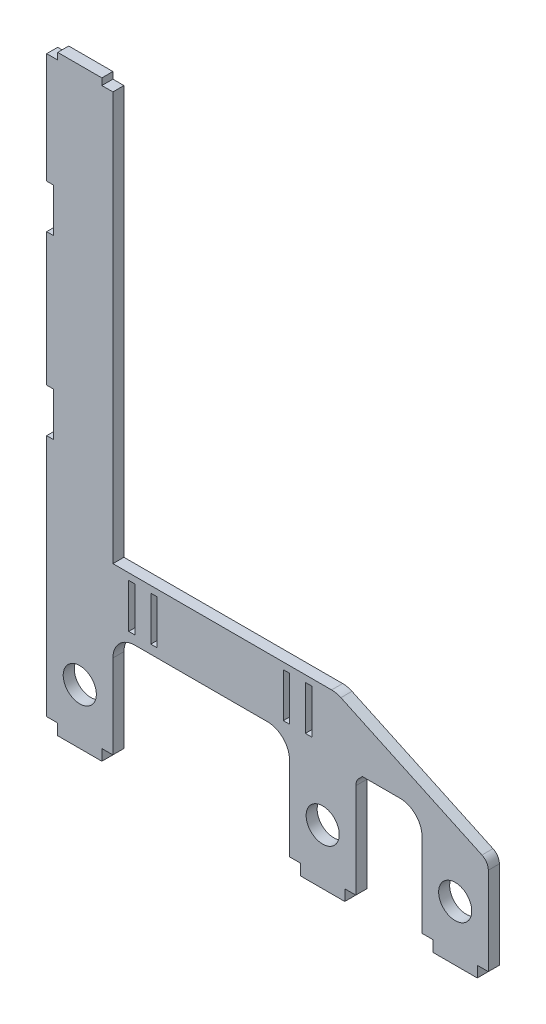
from build123d import *

# Parameters (mm, degrees)
SKETCH1_W           = 2.9
SKETCH1_H           = 20
BOSS_EXTRUDE1_DEPTH = 5
CUT_EXTRUDE1_DEPTH  = 6
FILLET1_R           = 10
SKETCH3_W           = 3
SKETCH3_H           = 19.8
CUT_EXTRUDE2_DEPTH  = 5
LPATTERN1_COUNT     = 2
LPATTERN1_PITCH     = 80
CUT_EXTRUDE3_DEPTH  = 10
CUT_EXTRUDE4_DEPTH  = 5
BOSS_EXTRUDE2_DEPTH = 5
BOSS_EXTRUDE3_DEPTH = 5
FILLET3_R           = 10
FILLET4_R           = 5
SKETCH12_W          = 20
SKETCH12_H          = 5
BOSS_EXTRUDE4_DEPTH = 5
SKETCH13_R          = 7.5
CUT_EXTRUDE6_DEPTH  = 6


with BuildPart() as part:
    # Sketch1 → Boss-Extrude1 (new body)
    with BuildSketch(Plane.XY):
        with BuildLine():
            Line((155, 62.071067812), (155, 65.538881442))
            ThreePointArc((155, 65.538881442), (153.730862151, 68.867645118), (150.567732956, 70.506544805))
            Line((150.567732956, 70.506544805), (34.432267044, 83.779169481))
            ThreePointArc((34.432267044, 83.779169481), (31.269137849, 85.418069168), (30, 88.746832844))
            Line((30, 88.746832844), (30, 260))
            Line((30, 260), (25, 260))
            Line((25, 260), (25, 263))
            Line((25, 263), (5, 263))
            Line((5, 263), (5, 260))
            Line((5, 260), (0, 260))
            Line((0, 260), (0, 0))
            Line((0, 0), (5, 0))
            Line((5, 0), (5, -5))
            Line((5, -5), (25, -5))
            Line((25, -5), (25, 0))
            Line((25, 0), (30, 0))
            Line((30, 0), (30, 40))
            ThreePointArc((30, 40), (31.464466094, 43.535533906), (35, 45))
            Line((35, 45), (105, 45))
            ThreePointArc((105, 45), (108.535533906, 43.535533906), (110, 40))
            Line((110, 40), (110, 0))
            Line((110, 0), (115, 0))
            Line((115, 0), (115, -5))
            Line((115, -5), (135, -5))
            Line((135, -5), (135, 0))
            Line((135, 0), (140, 0))
            Line((140, 0), (140, 42.928932188))
            ThreePointArc((140, 42.928932188), (140.380602337, 44.84234935), (141.464466094, 46.464466094))
            Line((141.464466094, 46.464466094), (153.535533906, 58.535533906))
            ThreePointArc((153.535533906, 58.535533906), (154.619397663, 60.15765065), (155, 62.071067812))
        make_face()
        with Locations((38.6, 62)):
            Rectangle(SKETCH1_W, SKETCH1_H, mode=Mode.SUBTRACT)
        with Locations((48.6, 62)):
            Rectangle(SKETCH1_W, SKETCH1_H, mode=Mode.SUBTRACT)
        with Locations((118.6, 62)):
            Rectangle(SKETCH1_W, SKETCH1_H, mode=Mode.SUBTRACT)
        with Locations((108.6, 62)):
            Rectangle(SKETCH1_W, SKETCH1_H, mode=Mode.SUBTRACT)
    extrude(amount=BOSS_EXTRUDE1_DEPTH)

    # Sketch2 → Cut-Extrude1 (cut, through all)
    with BuildSketch(Plane.XY.offset(5)):
        with BuildLine():
            Line((30, 40), (30, 48))
            Line((30, 48), (110, 48))
            Line((110, 48), (110, 40))
            ThreePointArc((110, 40), (108.535533906, 43.535533906), (105, 45))
            Line((105, 45), (35, 45))
            ThreePointArc((35, 45), (31.464466094, 43.535533906), (30, 40))
        make_face()
    extrude(amount=-CUT_EXTRUDE1_DEPTH, mode=Mode.SUBTRACT)

    # Fillet1
    fillet1_edges = [part.edges().sort_by_distance(p)[0] for p in [
        (30, 48, 2.5),
        (110, 48, 2.5),
    ]]
    fillet(fillet1_edges, radius=FILLET1_R)

    # Sketch3 → Cut-Extrude2 (cut)
    with BuildSketch(Plane(origin=(0, 0, 0), x_dir=(-1, 0, 0), z_dir=(0, 0, -1))):
        with Locations((-1.5, 200.1)):
            Rectangle(SKETCH3_W, SKETCH3_H)
    cut_extrude2 = extrude(amount=-CUT_EXTRUDE2_DEPTH, mode=Mode.SUBTRACT)

    # LPattern1: Cut-Extrude2 ×2
    with Locations(*[(0, -i * LPATTERN1_PITCH, 0) for i in range(1, LPATTERN1_COUNT)]):
        add(cut_extrude2, mode=Mode.SUBTRACT)

    # Sketch4 → Cut-Extrude3 (cut)
    with BuildSketch(Plane.XY.offset(5)):
        with BuildLine():
            Line((30, 88.746832844), (30, 75))
            Line((30, 75), (111.25, 75))
            Line((111.25, 75), (34.432267044, 83.779169481))
            ThreePointArc((34.432267044, 83.779169481), (31.269137849, 85.418069168), (30, 88.746832844))
        make_face()
    extrude(amount=-CUT_EXTRUDE3_DEPTH, mode=Mode.SUBTRACT)

    # Sketch5 → Cut-Extrude4 (cut)
    with BuildSketch(Plane.XY.offset(5)):
        with BuildLine():
            Line((150.567732956, 70.506544805), (134.9100099, 72.295998869))
            Line((134.9100099, 72.295998869), (153.535533906, 58.535533906))
            ThreePointArc((153.535533906, 58.535533906), (154.619397663, 60.15765065), (155, 62.071067812))
            Line((155, 62.071067812), (155, 65.538881442))
            ThreePointArc((155, 65.538881442), (153.730862151, 68.867645118), (150.567732956, 70.506544805))
        make_face()
    extrude(amount=-CUT_EXTRUDE4_DEPTH, mode=Mode.SUBTRACT)

    # Sketch5_3 → Boss-Extrude2 (add)
    with BuildSketch(Plane.XY.offset(5)):
        Polygon((131.25, 75), (111.25, 75), (134.9100099, 72.295998869), align=None)
    extrude(amount=-BOSS_EXTRUDE2_DEPTH)

    # Sketch10 → Boss-Extrude3 (add)
    with BuildSketch(Plane(origin=(0, 0, 0), x_dir=(-1, 0, 0), z_dir=(0, 0, -1))):
        Polygon((-131.25, 75), (-200, 42.941348502), (-200, 0), (-170, 0), (-170, 48), (-143, 48), (-153.535533906, 58.535533906), align=None)
    extrude(amount=-BOSS_EXTRUDE3_DEPTH)

    # Fillet3
    fillet3_edges = [part.edges().sort_by_distance(p)[0] for p in [
        (131.25, 75, 2.5),
        (170, 48, 2.5),
    ]]
    fillet(fillet3_edges, radius=FILLET3_R)

    # Fillet4
    fillet4_edges = [part.edges().sort_by_distance(p)[0] for p in [
        (200, 42.941348502, 2.5),
    ]]
    fillet(fillet4_edges, radius=FILLET4_R)

    # Sketch12 → Boss-Extrude4 (add)
    with BuildSketch(Plane.XY.offset(5)):
        with Locations((185, -2.5)):
            Rectangle(SKETCH12_W, SKETCH12_H)
    extrude(amount=-BOSS_EXTRUDE4_DEPTH)

    # Sketch13 → Cut-Extrude6 (cut, through all)
    with BuildSketch(Plane.XY.offset(5)):
        with Locations((15, 20)):
            Circle(SKETCH13_R)
        with Locations((125, 20)):
            Circle(SKETCH13_R)
        with Locations((185, 20)):
            Circle(SKETCH13_R)
    extrude(amount=-CUT_EXTRUDE6_DEPTH, mode=Mode.SUBTRACT)


solid = part.part
